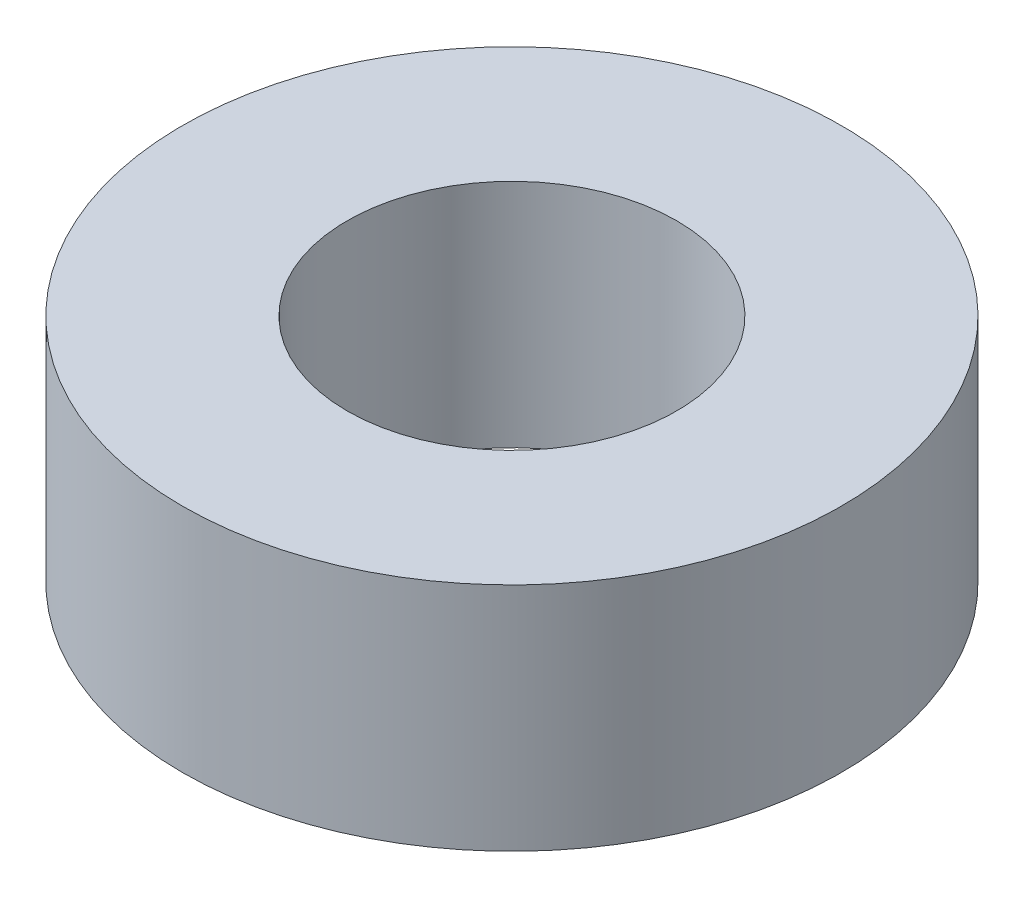
from build123d import *

# Parameters (mm, degrees)
SKETCH1_R           = 40
SKETCH1_R_2         = 20
BOSS_EXTRUDE1_DEPTH = 28


with BuildPart() as part:
    # Sketch1 → Boss-Extrude1 (new body)
    with BuildSketch(Plane(origin=(0, 0, 0), x_dir=(1, 0, 0), z_dir=(0, 1, 0))):
        Circle(SKETCH1_R)
        Circle(SKETCH1_R_2, mode=Mode.SUBTRACT)
    extrude(amount=BOSS_EXTRUDE1_DEPTH)


solid = part.part
